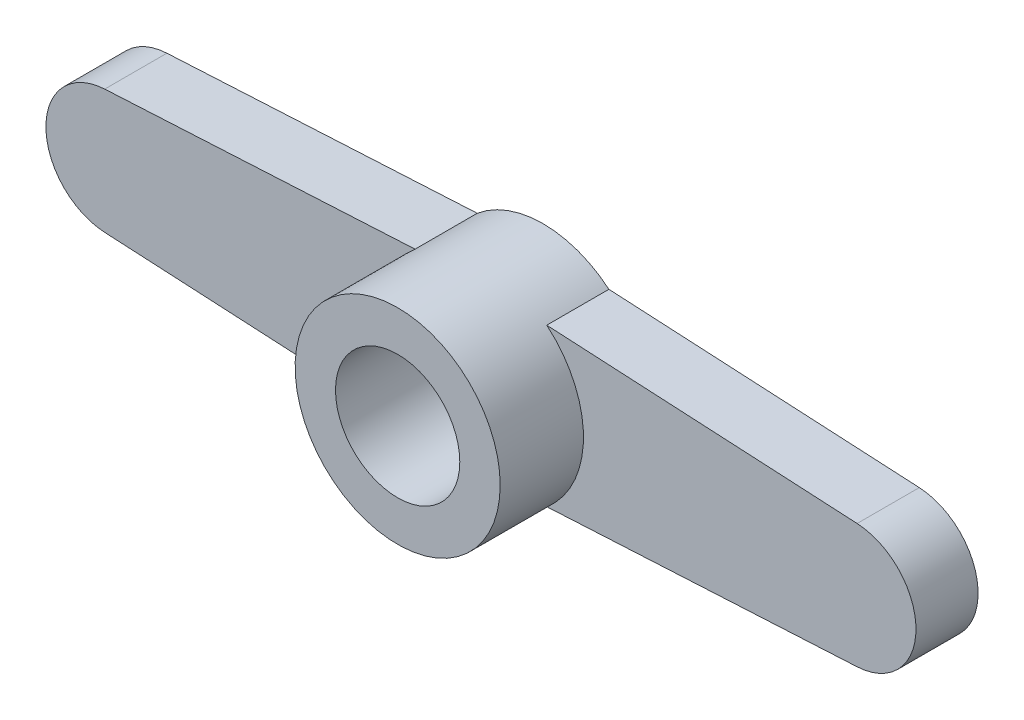
from build123d import *

# Parameters (mm, degrees)
SKETCH_1_R                 = 2
EXTRUDE_3_DEPTH            = 2
CROQUIS1_R                 = 3.3
CROQUIS1_R_2               = 2
SALIENTE_EXTRUIR1_DEPTH    = 2.68
SKETCH_5_R                 = 2.5
EXTRUDE_7_DEPTH            = 1
CROQUIS2_R                 = 1.25
CORTAR_EXTRUIR1_DEPTH      = 4.68
CORTAR_EXTRUIR1_DEPTH_BACK = 2
CROQUIS3_R                 = 2.35
CORTAR_EXTRUIR2_DEPTH      = 1


with BuildPart() as part:
    # Эскиз1 → Бобышка-Вытянуть3 (new body)
    with BuildSketch(Plane.XY):
        with BuildLine():
            Line((-2.118749631, 2.53), (-12.106546701, 1.997159934))
            ThreePointArc((-12.106546701, 1.997159934), (-14, 0), (-12.106546701, -1.997159934))
            Line((-12.106546701, -1.997159934), (-2.118749631, -2.53))
            ThreePointArc((-2.118749631, -2.53), (0, -3.3), (2.118749631, -2.53))
            Line((2.118749631, -2.53), (12.106546701, -1.997159934))
            ThreePointArc((12.106546701, -1.997159934), (14, 0), (12.106546701, 1.997159934))
            Line((12.106546701, 1.997159934), (2.118749631, 2.53))
            ThreePointArc((2.118749631, 2.53), (0, 3.3), (-2.118749631, 2.53))
        make_face()
        Circle(SKETCH_1_R, mode=Mode.SUBTRACT)
    extrude(amount=EXTRUDE_3_DEPTH)

    # Croquis1 → Saliente-Extruir1 (add)
    with BuildSketch(Plane.XY.offset(2)):
        Circle(CROQUIS1_R)
        Circle(CROQUIS1_R_2, mode=Mode.SUBTRACT)
    extrude(amount=SALIENTE_EXTRUIR1_DEPTH)

    # Эскиз5 → Бобышка-Вытянуть7 (add)
    with BuildSketch(Plane(origin=(0, 0, 0), x_dir=(-1, 0, 0), z_dir=(0, 0, -1))):
        Circle(SKETCH_5_R)
    extrude(amount=-EXTRUDE_7_DEPTH)

    # Croquis2 → Cortar-Extruir1 (cut, two sides)
    with BuildSketch(Plane.XY.offset(1)) as cortar_extruir1_sk:
        Circle(CROQUIS2_R)
    extrude(amount=CORTAR_EXTRUIR1_DEPTH, mode=Mode.SUBTRACT)
    extrude(cortar_extruir1_sk.sketch, amount=-CORTAR_EXTRUIR1_DEPTH_BACK, mode=Mode.SUBTRACT)

    # Croquis3 → Cortar-Extruir2 (cut)
    with BuildSketch(Plane(origin=(0, 0, 0), x_dir=(-1, 0, 0), z_dir=(0, 0, -1))):
        Circle(CROQUIS3_R)
    extrude(amount=-CORTAR_EXTRUIR2_DEPTH, mode=Mode.SUBTRACT)


solid = part.part
